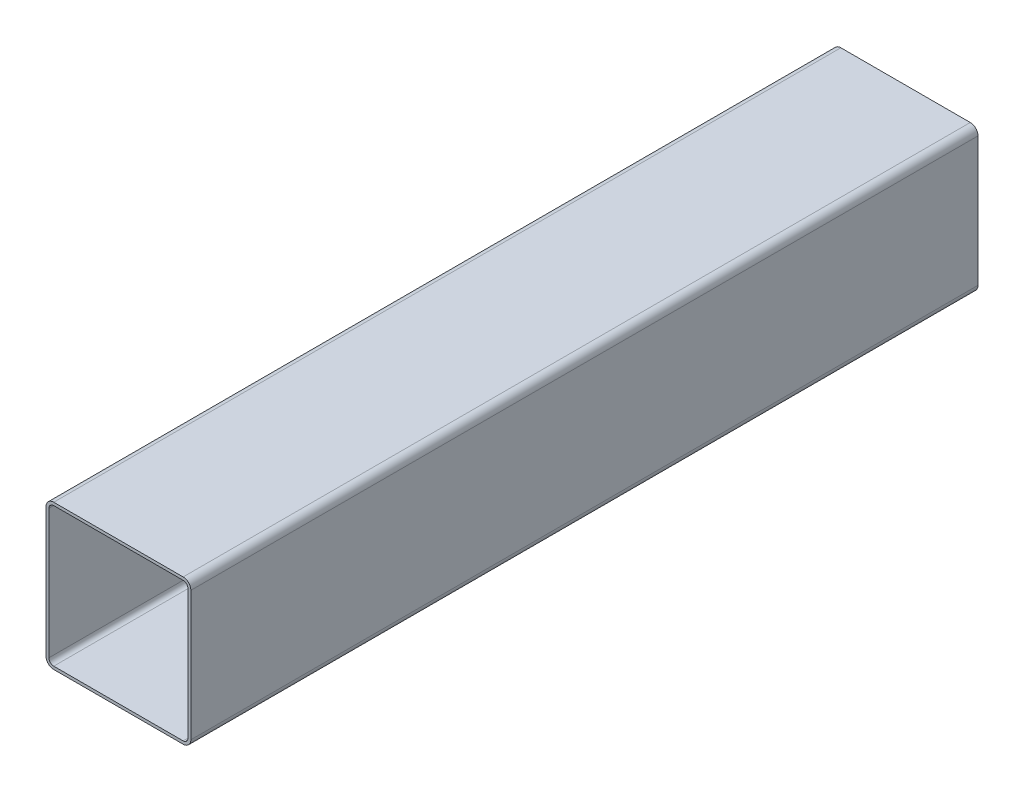
from build123d import *

# Parameters (mm, degrees)
EXTRUDE_1_DEPTH = 815


with BuildPart() as part:
    # Эскиз1 → Вытянуть-Тонкостенный1 (new body)
    with BuildSketch(Plane.XY):
        with BuildLine():
            Line((-67, 75), (67, 75))
            ThreePointArc((67, 75), (72.656854249, 72.656854249), (75, 67))
            Line((75, 67), (75, -67))
            ThreePointArc((75, -67), (72.656854249, -72.656854249), (67, -75))
            Line((67, -75), (-67, -75))
            ThreePointArc((-67, -75), (-72.656854249, -72.656854249), (-75, -67))
            Line((-75, -67), (-75, 67))
            ThreePointArc((-75, 67), (-72.656854249, 72.656854249), (-67, 75))
        make_face()
        with BuildLine():
            Line((-67, 72), (67, 72))
            ThreePointArc((67, 72), (70.535533906, 70.535533906), (72, 67))
            Line((72, 67), (72, -67))
            ThreePointArc((72, -67), (70.535533906, -70.535533906), (67, -72))
            Line((67, -72), (-67, -72))
            ThreePointArc((-67, -72), (-70.535533906, -70.535533906), (-72, -67))
            Line((-72, -67), (-72, 67))
            ThreePointArc((-72, 67), (-70.535533906, 70.535533906), (-67, 72))
        make_face(mode=Mode.SUBTRACT)
    extrude(amount=EXTRUDE_1_DEPTH)


solid = part.part
